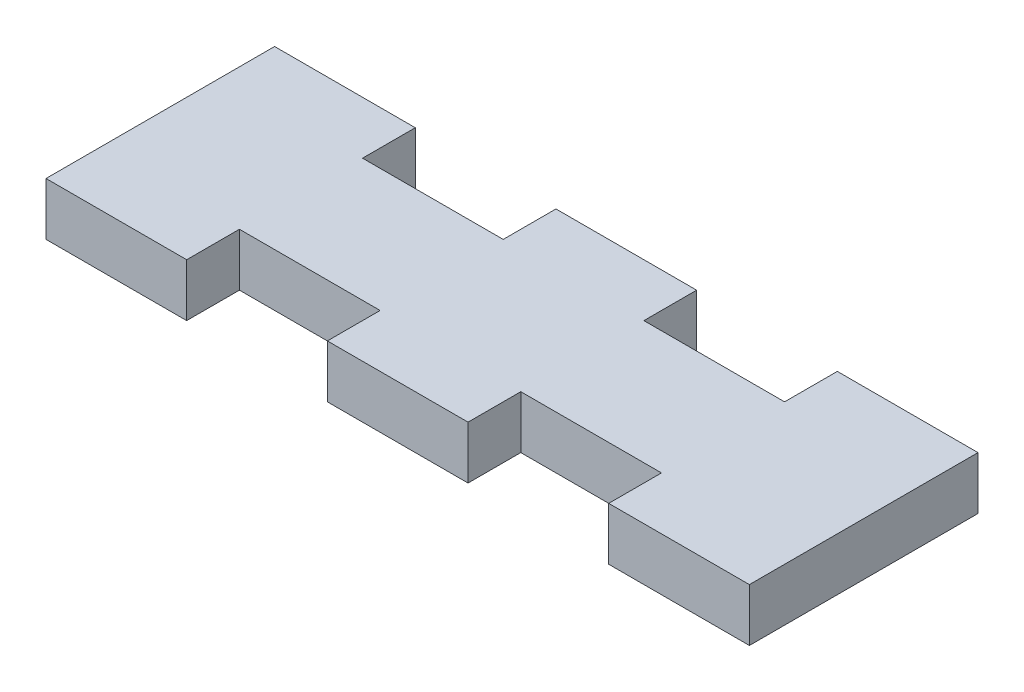
from build123d import *

# Parameters (mm, degrees)
ESTRUSIONE_ESTRUSIONE2_DEPTH = 1.5


with BuildPart() as part:
    # Schizzo3 → Estrusione-Estrusione2 (new body, symmetric)
    with BuildSketch(Plane(origin=(0, 0, 0), x_dir=(1, 0, 0), z_dir=(0, 1, 0))):
        Polygon((-20, -3.5), (-20, -6.5), (-12, -6.5), (-12, -3.5), (-4, -3.5), (-4, -6.5), (4, -6.5), (4, -3.5), (12, -3.5), (12, -6.5), (20, -6.5), (20, -3.5), (20, 3.5), (20, 6.5), (12, 6.5), (12, 3.5), (4, 3.5), (4, 6.5), (-4, 6.5), (-4, 3.5), (-12, 3.5), (-12, 6.5), (-20, 6.5), (-20, 3.5), align=None)
    extrude(amount=ESTRUSIONE_ESTRUSIONE2_DEPTH, both=True)


solid = part.part
